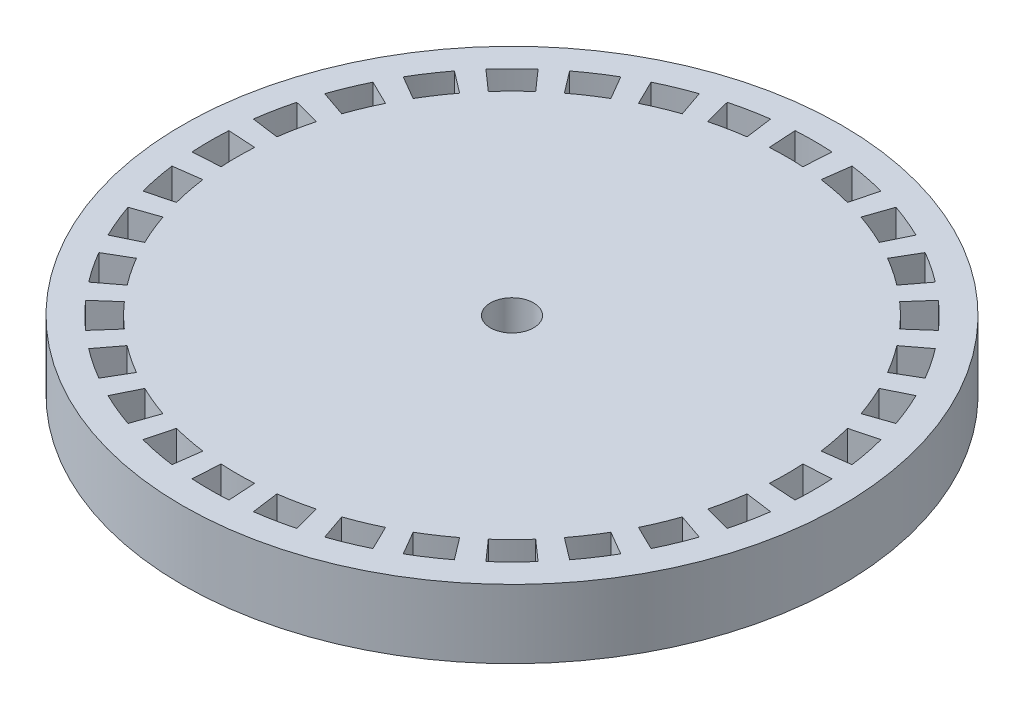
from build123d import *

# Parameters (mm, degrees)
SKETCH2_R           = 76.2
SKETCH2_R_2         = 5
BOSS_EXTRUDE1_DEPTH = 15.875
CUT_EXTRUDE1_DEPTH  = 16.875
CIRPATTERN1_COUNT   = 32


with BuildPart() as part:
    # Sketch2 → Boss-Extrude1 (new body)
    with BuildSketch(Plane(origin=(0, 0, 0), x_dir=(1, 0, 0), z_dir=(0, 1, 0))):
        Circle(SKETCH2_R)
        Circle(SKETCH2_R_2, mode=Mode.SUBTRACT)
    extrude(amount=BOSS_EXTRUDE1_DEPTH)

    # Sketch3 → Cut-Extrude1 (cut, through all)
    with BuildSketch(Plane(origin=(0, 15.875, 0), x_dir=(1, 0, 0), z_dir=(0, 1, 0))):
        with BuildLine():
            Line((-4.264240487, 69.71971567), (-3.87658226, 63.3815597))
            ThreePointArc((-3.87658226, 63.3815597), (0, 63.5), (3.87658226, 63.3815597))
            Line((3.87658226, 63.3815597), (4.264240487, 69.71971567))
            ThreePointArc((4.264240487, 69.71971567), (0, 69.85), (-4.264240487, 69.71971567))
        make_face()
    cut_extrude1 = extrude(amount=-CUT_EXTRUDE1_DEPTH, mode=Mode.SUBTRACT)

    # CirPattern1: Cut-Extrude1 ×32 about axis
    cirpattern1_axis = Axis((0, 0, 0), (0, 1, 0))
    for i in range(1, CIRPATTERN1_COUNT):
        add(cut_extrude1.rotate(cirpattern1_axis, i * 360 / CIRPATTERN1_COUNT), mode=Mode.SUBTRACT)


solid = part.part
